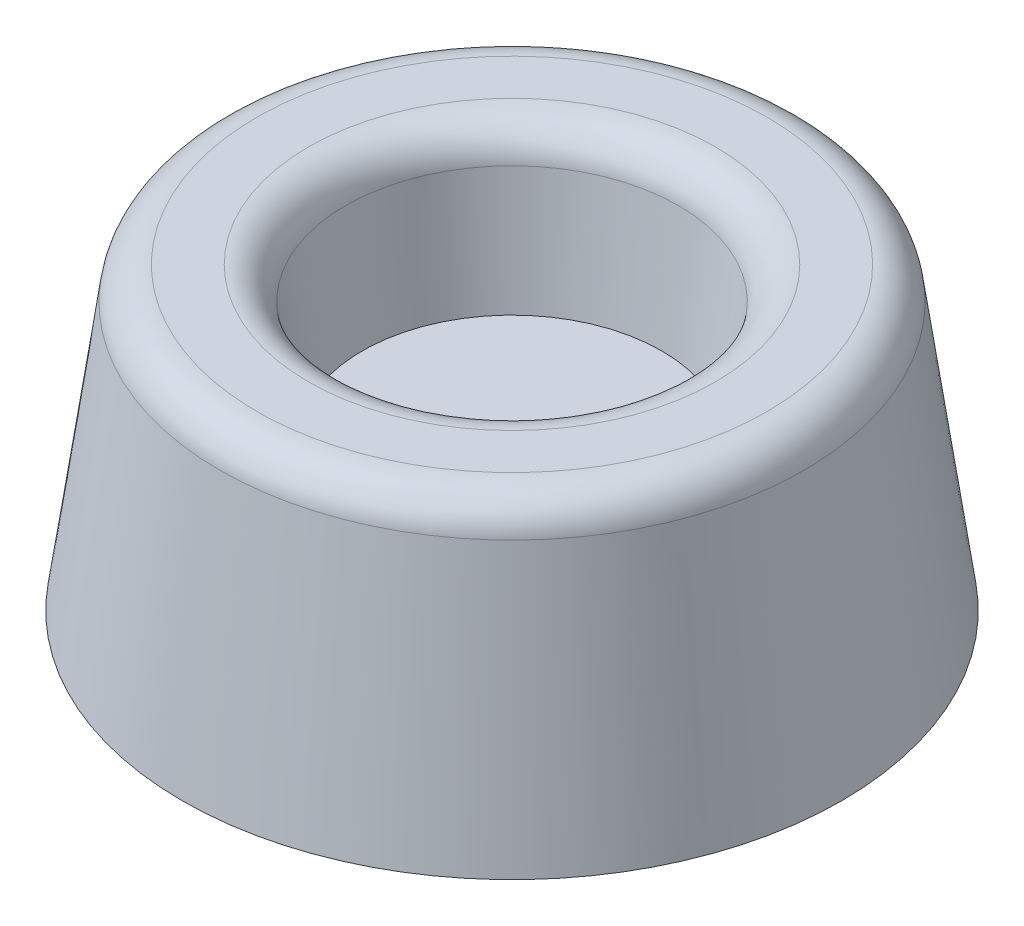
from build123d import *


with BuildPart() as part:
    # Sketch1 → Revolve1 (revolve)
    with BuildSketch(Plane(origin=(0, 0, 0), x_dir=(0, 0, -1), z_dir=(1, 0, 0))):
        with BuildLine():
            Line((0, 0), (11.176, 0))
            Line((11.176, 0), (9.90175141, 9.066749838))
            ThreePointArc((9.90175141, 9.066749838), (9.477305929, 9.848481167), (8.644110962, 10.16))
            Line((8.644110962, 10.16), (6.897941597, 10.16))
            ThreePointArc((6.897941597, 10.16), (6.06474663, 9.848481167), (5.64030115, 9.066749838))
            Line((5.64030115, 9.066749838), (5.08, 5.08))
            Line((5.08, 5.08), (0, 5.08))
            Line((0, 5.08), (0, 0))
        make_face()
    revolve(axis=Axis((0, 0, 0), (0, 1, 0)))


solid = part.part
